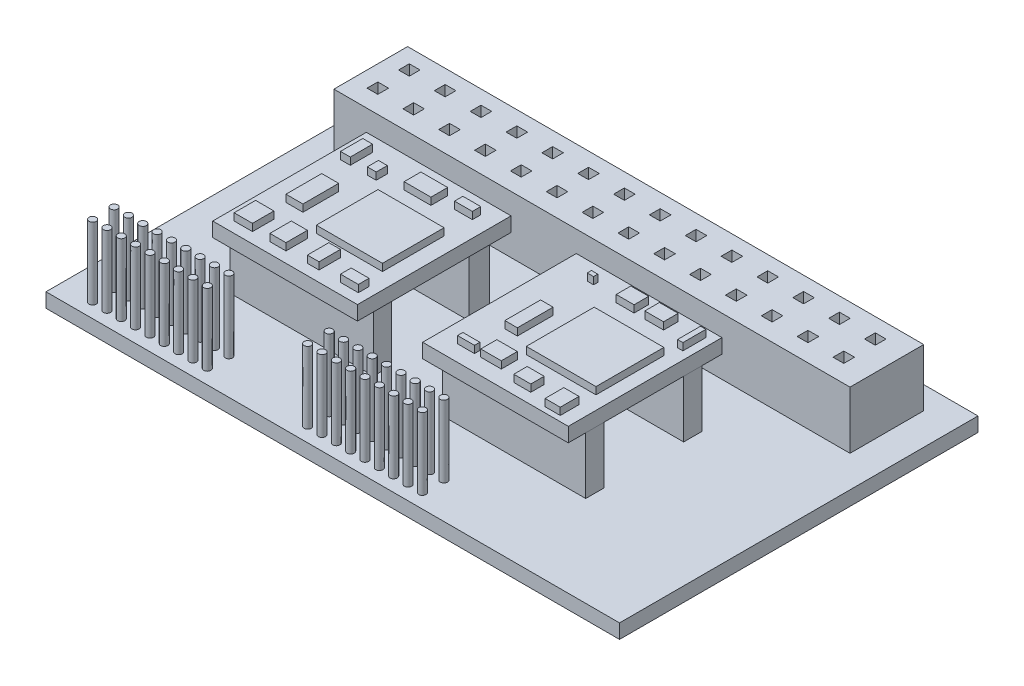
from build123d import *

# Parameters (mm, degrees)
SKETCH_1_W      = 80
SKETCH_1_H      = 50
EXTRUDE_1_DEPTH = 2
SKETCH_2_W      = 71.990611176
SKETCH_2_H      = 10.284373025
SKETCH_2_W_2    = 1.5
SKETCH_2_H_2    = 1.5
EXTRUDE_2_DEPTH = 8
SKETCH_3_R      = 0.5
EXTRUDE_3_DEPTH = 10
SKETCH_5_W      = 20
SKETCH_5_H      = 2.54
SKETCH_5_H_2    = 2.866211032
EXTRUDE_4_DEPTH = 8
SKETCH_6_W      = 20.188095099
SKETCH_6_H      = 21.434273809
SKETCH_6_W_2    = 20.31271297
EXTRUDE_5_DEPTH = 2
SKETCH_7_W      = 2.367739548
SKETCH_7_H      = 4.984714839
SKETCH_7_W_2    = 1.744650194
SKETCH_7_W_3    = 9.221722452
SKETCH_7_H_2    = 8.598633098
SKETCH_7_W_4    = 9.720193937
SKETCH_7_H_3    = 9.470958195
SKETCH_7_W_5    = 2.554666355
SKETCH_7_H_4    = 2.990828904
SKETCH_7_W_6    = 2.243121678
SKETCH_7_W_7    = 1.620032323
SKETCH_7_W_8    = 2.492357419
SKETCH_7_H_5    = 1.495414452
SKETCH_7_W_9    = 1.370796581
SKETCH_7_H_6    = 3.115446774
SKETCH_7_W_10   = 1.24617871
SKETCH_7_H_7    = 1.557723387
SKETCH_7_W_11   = 3.738536129
SKETCH_7_H_8    = 2.336585081
SKETCH_7_H_9    = 1.16829254
SKETCH_7_W_12   = 0.872325097
SKETCH_7_H_10   = 0.58414627
SKETCH_7_W_13   = 2.49235742
SKETCH_7_H_11   = 2.040617637
SKETCH_7_W_14   = 2.61697529
SKETCH_7_W_15   = 0.747707226
SKETCH_7_H_12   = 3.208910178
SKETCH_7_W_16   = 2.367739549
SKETCH_7_H_13   = 0.747707226
SKETCH_7_W_17   = 2.866211032
SKETCH_7_H_14   = 2.243121678
SKETCH_7_H_15   = 1.869268065
SKETCH_7_W_18   = 2.118503807
SKETCH_7_H_16   = 2.616975291
EXTRUDE_6_DEPTH = 1


with BuildPart() as part:
    # 草图1 → 凸台-拉伸1 (new body)
    with BuildSketch(Plane(origin=(0, 0, 0), x_dir=(1, 0, 0), z_dir=(0, 1, 0))):
        with Locations((40, 25)):
            Rectangle(SKETCH_1_W, SKETCH_1_H)
    extrude(amount=EXTRUDE_1_DEPTH)

    # 草图2 → 凸台-拉伸2 (add)
    with BuildSketch(Plane(origin=(0, 2, 0), x_dir=(1, 0, 0), z_dir=(0, 1, 0))):
        with Locations((39.595558364, 41.697661822)):
            Rectangle(SKETCH_2_W, SKETCH_2_H)
        with Locations((11.545793085, 39.734336914)):
            Rectangle(SKETCH_2_W_2, SKETCH_2_H_2, mode=Mode.SUBTRACT)
        with Locations((6.545793085, 44.125417532)):
            Rectangle(SKETCH_2_W_2, SKETCH_2_H_2, mode=Mode.SUBTRACT)
        with Locations((6.545793085, 39.734336914)):
            Rectangle(SKETCH_2_W_2, SKETCH_2_H_2, mode=Mode.SUBTRACT)
        with Locations((11.545793085, 44.125417532)):
            Rectangle(SKETCH_2_W_2, SKETCH_2_H_2, mode=Mode.SUBTRACT)
        with Locations((16.545793085, 39.734336914)):
            Rectangle(SKETCH_2_W_2, SKETCH_2_H_2, mode=Mode.SUBTRACT)
        with Locations((16.545793085, 44.125417532)):
            Rectangle(SKETCH_2_W_2, SKETCH_2_H_2, mode=Mode.SUBTRACT)
        with Locations((21.545793085, 39.734336914)):
            Rectangle(SKETCH_2_W_2, SKETCH_2_H_2, mode=Mode.SUBTRACT)
        with Locations((21.545793085, 44.125417532)):
            Rectangle(SKETCH_2_W_2, SKETCH_2_H_2, mode=Mode.SUBTRACT)
        with Locations((26.545793085, 39.734336914)):
            Rectangle(SKETCH_2_W_2, SKETCH_2_H_2, mode=Mode.SUBTRACT)
        with Locations((26.545793085, 44.125417532)):
            Rectangle(SKETCH_2_W_2, SKETCH_2_H_2, mode=Mode.SUBTRACT)
        with Locations((31.545793085, 39.734336914)):
            Rectangle(SKETCH_2_W_2, SKETCH_2_H_2, mode=Mode.SUBTRACT)
        with Locations((31.545793085, 44.125417532)):
            Rectangle(SKETCH_2_W_2, SKETCH_2_H_2, mode=Mode.SUBTRACT)
        with Locations((36.545793085, 39.734336914)):
            Rectangle(SKETCH_2_W_2, SKETCH_2_H_2, mode=Mode.SUBTRACT)
        with Locations((36.545793085, 44.125417532)):
            Rectangle(SKETCH_2_W_2, SKETCH_2_H_2, mode=Mode.SUBTRACT)
        with Locations((41.545793085, 39.734336914)):
            Rectangle(SKETCH_2_W_2, SKETCH_2_H_2, mode=Mode.SUBTRACT)
        with Locations((41.545793085, 44.125417532)):
            Rectangle(SKETCH_2_W_2, SKETCH_2_H_2, mode=Mode.SUBTRACT)
        with Locations((46.545793085, 39.734336914)):
            Rectangle(SKETCH_2_W_2, SKETCH_2_H_2, mode=Mode.SUBTRACT)
        with Locations((46.545793085, 44.125417532)):
            Rectangle(SKETCH_2_W_2, SKETCH_2_H_2, mode=Mode.SUBTRACT)
        with Locations((51.545793085, 39.734336914)):
            Rectangle(SKETCH_2_W_2, SKETCH_2_H_2, mode=Mode.SUBTRACT)
        with Locations((51.545793085, 44.125417532)):
            Rectangle(SKETCH_2_W_2, SKETCH_2_H_2, mode=Mode.SUBTRACT)
        with Locations((56.545793085, 39.734336914)):
            Rectangle(SKETCH_2_W_2, SKETCH_2_H_2, mode=Mode.SUBTRACT)
        with Locations((56.545793085, 44.125417532)):
            Rectangle(SKETCH_2_W_2, SKETCH_2_H_2, mode=Mode.SUBTRACT)
        with Locations((61.545793085, 39.734336914)):
            Rectangle(SKETCH_2_W_2, SKETCH_2_H_2, mode=Mode.SUBTRACT)
        with Locations((61.545793085, 44.125417532)):
            Rectangle(SKETCH_2_W_2, SKETCH_2_H_2, mode=Mode.SUBTRACT)
        with Locations((66.545793085, 39.734336914)):
            Rectangle(SKETCH_2_W_2, SKETCH_2_H_2, mode=Mode.SUBTRACT)
        with Locations((66.545793085, 44.125417532)):
            Rectangle(SKETCH_2_W_2, SKETCH_2_H_2, mode=Mode.SUBTRACT)
        with Locations((71.545793085, 39.734336914)):
            Rectangle(SKETCH_2_W_2, SKETCH_2_H_2, mode=Mode.SUBTRACT)
        with Locations((71.545793085, 44.125417532)):
            Rectangle(SKETCH_2_W_2, SKETCH_2_H_2, mode=Mode.SUBTRACT)
    extrude(amount=EXTRUDE_2_DEPTH)

    # 草图3 → 凸台-拉伸3 (add)
    with BuildSketch(Plane(origin=(0, 2, 0), x_dir=(1, 0, 0), z_dir=(0, 1, 0))):
        with Locations((4.5, 2)):
            Circle(SKETCH_3_R)
        with Locations((4.5, 5)):
            Circle(SKETCH_3_R)
        with Locations((6.5, 2)):
            Circle(SKETCH_3_R)
        with Locations((6.5, 5)):
            Circle(SKETCH_3_R)
        with Locations((8.5, 2)):
            Circle(SKETCH_3_R)
        with Locations((8.5, 5)):
            Circle(SKETCH_3_R)
        with Locations((10.5, 2)):
            Circle(SKETCH_3_R)
        with Locations((10.5, 5)):
            Circle(SKETCH_3_R)
        with Locations((12.5, 2)):
            Circle(SKETCH_3_R)
        with Locations((12.5, 5)):
            Circle(SKETCH_3_R)
        with Locations((14.5, 2)):
            Circle(SKETCH_3_R)
        with Locations((14.5, 5)):
            Circle(SKETCH_3_R)
        with Locations((16.5, 2)):
            Circle(SKETCH_3_R)
        with Locations((16.5, 5)):
            Circle(SKETCH_3_R)
        with Locations((18.5, 2)):
            Circle(SKETCH_3_R)
        with Locations((18.5, 5)):
            Circle(SKETCH_3_R)
        with Locations((20.5, 2)):
            Circle(SKETCH_3_R)
        with Locations((20.5, 5)):
            Circle(SKETCH_3_R)
        with Locations((34.5, 2)):
            Circle(SKETCH_3_R)
        with Locations((34.5, 5)):
            Circle(SKETCH_3_R)
        with Locations((36.5, 2)):
            Circle(SKETCH_3_R)
        with Locations((36.5, 5)):
            Circle(SKETCH_3_R)
        with Locations((38.5, 2)):
            Circle(SKETCH_3_R)
        with Locations((38.5, 5)):
            Circle(SKETCH_3_R)
        with Locations((40.5, 2)):
            Circle(SKETCH_3_R)
        with Locations((40.5, 5)):
            Circle(SKETCH_3_R)
        with Locations((42.5, 2)):
            Circle(SKETCH_3_R)
        with Locations((42.5, 5)):
            Circle(SKETCH_3_R)
        with Locations((44.5, 2)):
            Circle(SKETCH_3_R)
        with Locations((44.5, 5)):
            Circle(SKETCH_3_R)
        with Locations((46.5, 2)):
            Circle(SKETCH_3_R)
        with Locations((46.5, 5)):
            Circle(SKETCH_3_R)
        with Locations((48.5, 2)):
            Circle(SKETCH_3_R)
        with Locations((48.5, 5)):
            Circle(SKETCH_3_R)
        with Locations((50.5, 2)):
            Circle(SKETCH_3_R)
        with Locations((50.5, 5)):
            Circle(SKETCH_3_R)
    extrude(amount=EXTRUDE_3_DEPTH)

    # 草图5 → 凸台-拉伸4 (add)
    with BuildSketch(Plane(origin=(0, 2, 0), x_dir=(1, 0, 0), z_dir=(0, 1, 0))):
        with Locations((23.021399225, 13.932830773)):
            Rectangle(SKETCH_5_W, SKETCH_5_H)
        with Locations((23.021399225, 27.430048484)):
            Rectangle(SKETCH_5_W, SKETCH_5_H_2)
        with Locations((52.616975291, 13.932830773)):
            Rectangle(SKETCH_5_W, SKETCH_5_H)
        with Locations((52.616975291, 27.593154)):
            Rectangle(SKETCH_5_W, SKETCH_5_H)
    extrude(amount=EXTRUDE_4_DEPTH)

    # 草图6 → 凸台-拉伸5 (add)
    with BuildSketch(Plane(origin=(0, 10, 0), x_dir=(1, 0, 0), z_dir=(0, 1, 0))):
        with Locations((23.176587418, 20.887610258)):
            Rectangle(SKETCH_6_W, SKETCH_6_H)
        with Locations((52.524096034, 20.887610258)):
            Rectangle(SKETCH_6_W_2, SKETCH_6_H)
    extrude(amount=EXTRUDE_5_DEPTH)

    # 草图7 → 凸台-拉伸6 (add)
    with BuildSketch(Plane(origin=(0, 12, 0), x_dir=(1, 0, 0), z_dir=(0, 1, 0))):
        with Locations((17.132620675, 20.01528516)):
            Rectangle(SKETCH_7_W, SKETCH_7_H)
        with Locations((47.352454388, 20.01528516)):
            Rectangle(SKETCH_7_W_2, SKETCH_7_H)
        with Locations((26.416652063, 20.202211967)):
            Rectangle(SKETCH_7_W_3, SKETCH_7_H_2)
        with Locations((55.951087486, 20.638374516)):
            Rectangle(SKETCH_7_W_4, SKETCH_7_H_3)
        with Locations((15.855287498, 13.161302257)):
            Rectangle(SKETCH_7_W_5, SKETCH_7_H_4)
        with Locations((20.684229998, 13.161302257)):
            Rectangle(SKETCH_7_W_6, SKETCH_7_H_4)
        with Locations((25.606635901, 13.161302257)):
            Rectangle(SKETCH_7_W_7, SKETCH_7_H_4)
        with Locations((30.653659677, 12.413595031)):
            Rectangle(SKETCH_7_W_8, SKETCH_7_H_5)
        with Locations((15.263352611, 28.053137839)):
            Rectangle(SKETCH_7_W_9, SKETCH_7_H_6)
        with Locations((18.939579804, 27.274276146)):
            Rectangle(SKETCH_7_W_10, SKETCH_7_H_7)
        with Locations((24.547383999, 28.442568685)):
            Rectangle(SKETCH_7_W_11, SKETCH_7_H_8)
        with Locations((29.78133458, 29.026714956)):
            Rectangle(SKETCH_7_W_8, SKETCH_7_H_9)
        with Locations((46.91629184, 29.318788091)):
            Rectangle(SKETCH_7_W_12, SKETCH_7_H_10)
        with Locations((52.337169227, 29.462877504)):
            Rectangle(SKETCH_7_W_13, SKETCH_7_H_11)
        with Locations((56.387250034, 29.462877504)):
            Rectangle(SKETCH_7_W_14, SKETCH_7_H_11)
        with Locations((61.185038067, 28.878731234)):
            Rectangle(SKETCH_7_W_15, SKETCH_7_H_12)
        with Locations((46.168584614, 12.787448644)):
            Rectangle(SKETCH_7_W_16, SKETCH_7_H_13)
        with Locations((49.657885001, 13.53515587)):
            Rectangle(SKETCH_7_W_17, SKETCH_7_H_14)
        with Locations((54.767217712, 12.600521838)):
            Rectangle(SKETCH_7_W_16, SKETCH_7_H_15)
        with Locations((59.751932551, 12.226668225)):
            Rectangle(SKETCH_7_W_18, SKETCH_7_H_16)
    extrude(amount=EXTRUDE_6_DEPTH)


solid = part.part
